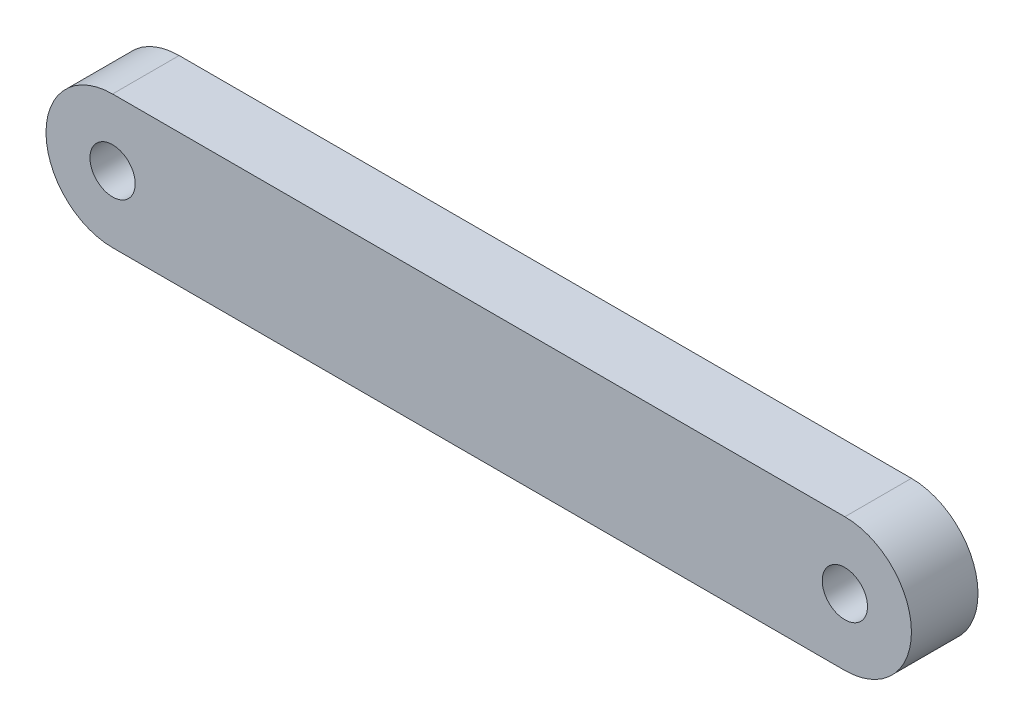
from build123d import *

# Parameters (mm, degrees)
SKETCH1_R           = 2.159
BOSS_EXTRUDE1_DEPTH = 6.35


with BuildPart() as part:
    # Sketch1 → Boss-Extrude1 (new body)
    with BuildSketch(Plane.XY):
        with BuildLine():
            Line((0, 6.35), (69.85, 6.35))
            ThreePointArc((69.85, 6.35), (76.2, 0), (69.85, -6.35))
            Line((69.85, -6.35), (0, -6.35))
            ThreePointArc((0, -6.35), (-6.35, 0), (0, 6.35))
        make_face()
        Circle(SKETCH1_R, mode=Mode.SUBTRACT)
        with Locations((69.85, 0)):
            Circle(SKETCH1_R, mode=Mode.SUBTRACT)
    extrude(amount=BOSS_EXTRUDE1_DEPTH)


solid = part.part
